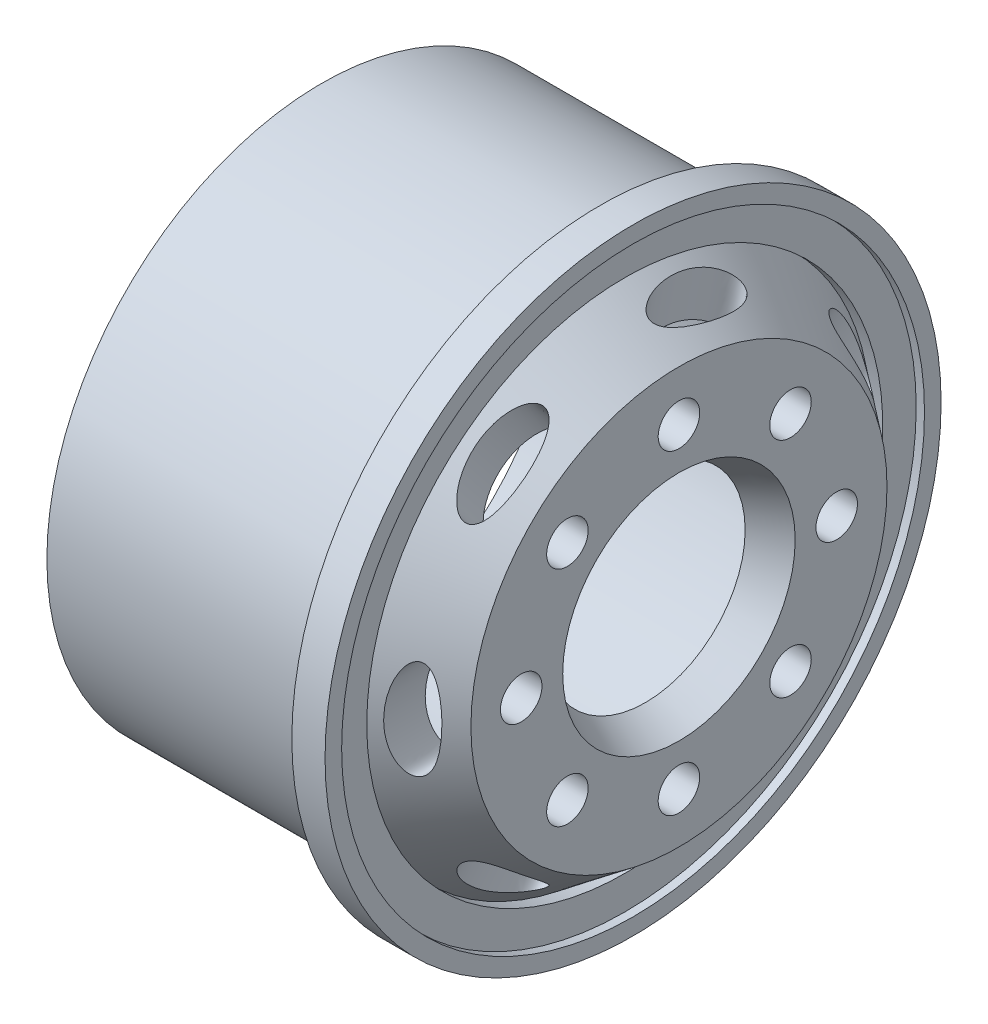
from build123d import *

# Parameters (mm, degrees)
SKETCH2_R          = 1.25
CUT_EXTRUDE1_DEPTH = 34.926441495
CUT_EXTRUDE2_REACH = 42.343
SKETCH3_RX         = 3
SKETCH3_RY         = 1
CIRPATTERN1_COUNT  = 7


with BuildPart() as part:
    # Sketch1 → Revolve1 (revolve)
    with BuildSketch(Plane(origin=(0, 0, 0), x_dir=(1, 0, 0), z_dir=(0, 1, 0)), mode=Mode.PRIVATE) as revolve1_sk:
        Polygon((-12.563694364, 14.55), (-12.563694364, 16.55), (4.186305636, 16.55), (4.186305636, 18.55), (5.686305636, 18.55), (6.186305636, 18.55), (6.186305636, 17.55), (5.686305636, 17.55), (5.686305636, 15.537968137), (4.955330367, 15.537968137), (8.9490561, 12.528479936), (8.9490561, 7), (6.936305636, 6), (6.936305636, 11.540924884), (2.943128086, 14.55), align=None)
    revolve(revolve1_sk.sketch.rotate(Axis((-37.278866169, 0, 0), (1, 0, 0)), 180), axis=Axis((-37.278866169, 0, 0), (1, 0, 0)))

    # Sketch2 → Cut-Extrude1 (cut, through all)
    with BuildSketch(Plane(origin=(8.9490561, 0, 0), x_dir=(0, 0, -1), z_dir=(1, 0, 0))):
        with Locations((0, 9.5)):
            Circle(SKETCH2_R)
        with Locations((6.717514421, 6.717514421)):
            Circle(SKETCH2_R)
        with Locations((9.5, 0)):
            Circle(SKETCH2_R)
        with Locations((6.717514421, -6.717514421)):
            Circle(SKETCH2_R)
        with Locations((0, -9.5)):
            Circle(SKETCH2_R)
        with Locations((-6.717514421, -6.717514421)):
            Circle(SKETCH2_R)
        with Locations((-9.5, 0)):
            Circle(SKETCH2_R)
        with Locations((-6.717514421, 6.717514421)):
            Circle(SKETCH2_R)
    extrude(amount=-CUT_EXTRUDE1_DEPTH, mode=Mode.SUBTRACT)

    # Cut-Extrude2: up to this cone (the profile starts outside it)
    cut_extrude2_end = Plane(origin=(6.952193, 0, 0), z_dir=(-1, 0, 0)).offset(-15.29943624) * Cone(1e-06, 52.501158214, 69.671389137, align=(Align.CENTER, Align.CENTER, Align.MIN), mode=Mode.PRIVATE)
    # Sketch3 → Cut-Extrude2 (cut, up to the surface)
    with BuildSketch(Plane.XY.offset(15), mode=Mode.PRIVATE) as cut_extrude2_sk1:
        with Locations(Location((6.952193234, 0), (0, 0, -90))):
            Ellipse(SKETCH3_RX, SKETCH3_RY)
    cut_extrude2_tool1 = extrude(cut_extrude2_sk1.sketch, amount=-CUT_EXTRUDE2_REACH, mode=Mode.PRIVATE) - cut_extrude2_end
    cut_extrude2 = cut_extrude2_tool1.solids().sort_by_distance((6.952193, 0, 15))[0]
    add(cut_extrude2, mode=Mode.SUBTRACT)

    # CirPattern1: Cut-Extrude2 ×7 about axis
    cirpattern1_axis = Axis((8.9490561, 0, 0), (-1, 0, 0))
    for i in range(1, CIRPATTERN1_COUNT):
        add(cut_extrude2.rotate(cirpattern1_axis, i * 360 / CIRPATTERN1_COUNT), mode=Mode.SUBTRACT)


solid = part.part
